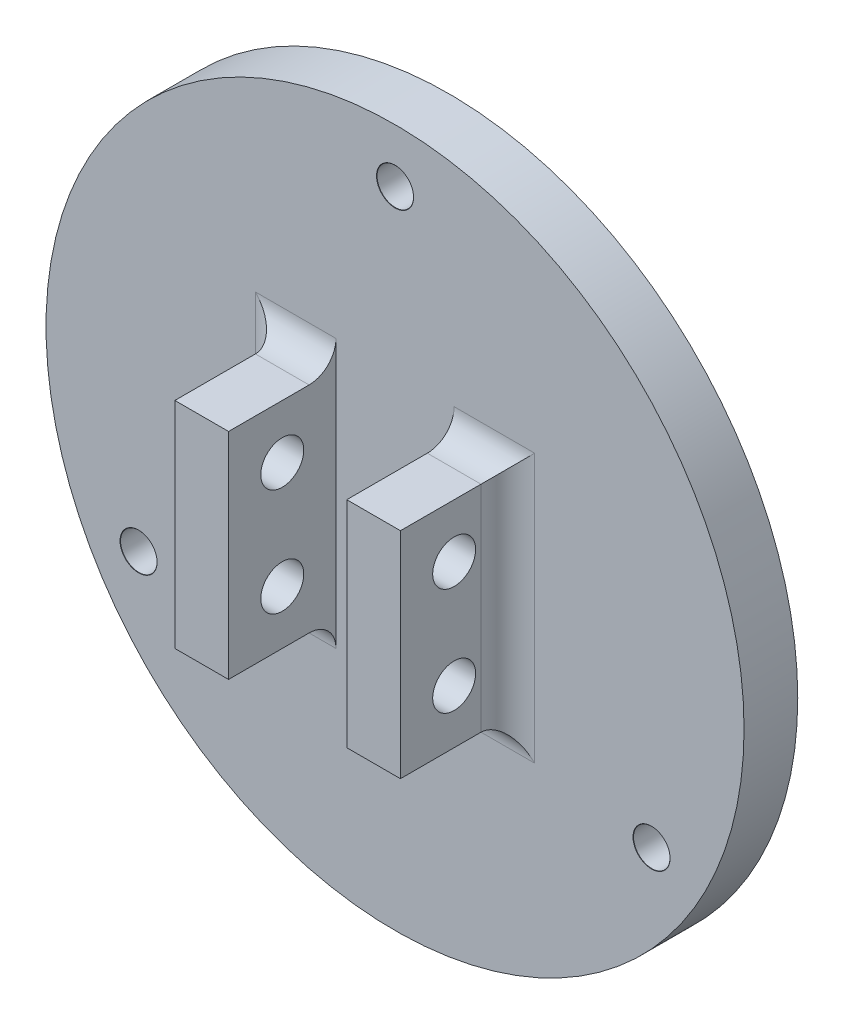
from build123d import *

# Parameters (mm, degrees)
SKETCH_1_R                     = 32.5
EXTRUDE_1_DEPTH                = 5
PATTERN_CIRCULAR_1_COUNT       = 3
SKETCH_5_W                     = 5
SKETCH_5_H                     = 20
EXTRUDE_2_DEPTH                = 10
HOLE_WIZARD_M3_1_2_D           = 3.4
HOLE_WIZARD_M3_1_2_CBORE_D     = 6.5
HOLE_WIZARD_M3_1_2_CBORE_DEPTH = 3.4
F_4_0MM_1_D                    = 4
FILLET_1_R                     = 2.5
FILLET_2_R                     = 2.5


with BuildPart() as part:
    # 스케치1 → 보스-돌출1 (new body)
    with BuildSketch(Plane.XY):
        Circle(SKETCH_1_R)
    extrude(amount=EXTRUDE_1_DEPTH)

    # 스케치4 → Hole Wizard M3 _ _1 (revolve, cut)
    with BuildSketch(Plane(origin=(0, 27.5, 5), x_dir=(0, -1, 0), z_dir=(1, 0, 0))):
        Polygon((0, 0), (0, 6.021463052), (1.7, 5), (1.7, 0.020977491), (1.725, 0), align=None)
    hole_wizard_m3_1 = revolve(axis=Axis((0, 27.5, 11.35), (0, 0, -1)), mode=Mode.SUBTRACT)

    # 원형 패턴1: Hole Wizard M3 _ _1 ×3 about axis
    pattern_circular_1_axis = Axis((0, -0.077690761, 0), (0, 0, 1))
    for i in range(1, PATTERN_CIRCULAR_1_COUNT):
        add(hole_wizard_m3_1.rotate(pattern_circular_1_axis, i * 360 / PATTERN_CIRCULAR_1_COUNT), mode=Mode.SUBTRACT)

    # 스케치5 → 보스-돌출2 (add)
    with BuildSketch(Plane.XY.offset(5)):
        with Locations((-8.003327874, 0)):
            Rectangle(SKETCH_5_W, SKETCH_5_H)
        with Locations((8.003327874, 0)):
            Rectangle(SKETCH_5_W, SKETCH_5_H)
    extrude(amount=EXTRUDE_2_DEPTH)

    # Hole Wizard M3 _ _ _ _ _ _1 2 (through all)
    with Locations(Plane(origin=(0, 0, 0), x_dir=(-1, 0, 0), z_dir=(0, 0, -1))):
        with Locations((0, 0)):
            CounterBoreHole(HOLE_WIZARD_M3_1_2_D / 2, HOLE_WIZARD_M3_1_2_CBORE_D / 2, HOLE_WIZARD_M3_1_2_CBORE_DEPTH)

    # Ø4.0mm 맞춤핀 구멍1 (through all)
    with Locations(Plane.ZY.offset(10.503327874)):
        with Locations((10, 5), (10, -5)):
            Hole(F_4_0MM_1_D / 2)

    # 필렛1
    fillet_1_edges = [part.edges().sort_by_distance(p)[0] for p in [
        (-10.503327874, 0, 5),
        (10.503327874, 0, 5),
    ]]
    fillet(fillet_1_edges, radius=FILLET_1_R)

    # 필렛2
    fillet_2_edges = [part.edges().sort_by_distance(p)[0] for p in [
        (8.003327874, -10, 5),
        (-8.003327874, -10, 5),
        (8.003327874, 10, 5),
        (-8.003327874, 10, 5),
    ]]
    fillet(fillet_2_edges, radius=FILLET_2_R)


solid = part.part
